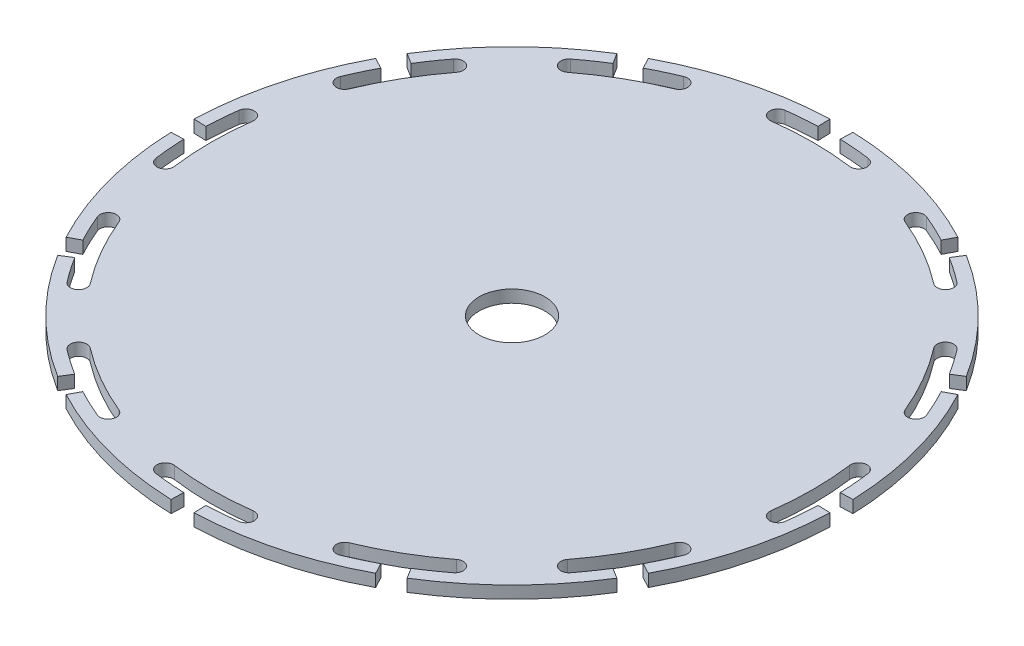
from build123d import *

# Parameters (mm, degrees)
SKETCH1_R         = 40
WHEEL_BLANK_DEPTH = 1.5
T_SLOT_DEPTH      = 2.5
CIRPATTERN_COUNT  = 12
SKETCH3_R         = 4
CENTER_HOLE_DEPTH = 6


with BuildPart() as part:
    # Sketch1 → Wheel Blank (new body)
    with BuildSketch(Plane(origin=(0, 0, 0), x_dir=(1, 0, 0), z_dir=(0, 1, 0))):
        Circle(SKETCH1_R)
    extrude(amount=WHEEL_BLANK_DEPTH)

    # Sketch2 → T-Slot (cut, through all)
    with BuildSketch(Plane(origin=(0, 0, 0), x_dir=(1, 0, 0), z_dir=(0, 1, 0))):
        with BuildLine():
            Line((-1.395979868, 39.975633081), (-1.343630623, 38.47654684))
            ThreePointArc((-1.343630623, 38.47654684), (-3.188115989, 38.367771846), (-5.0252584, 38.170627163))
            ThreePointArc((-5.0252584, 38.170627163), (-5.88617707, 37.048656109), (-4.764206016, 36.18773744))
            ThreePointArc((-4.764206016, 36.18773744), (0, 36.5), (4.764206016, 36.18773744))
            ThreePointArc((4.764206016, 36.18773744), (5.88617707, 37.048656109), (5.0252584, 38.170627163))
            ThreePointArc((5.0252584, 38.170627163), (3.188115989, 38.367771846), (1.343630623, 38.47654684))
            Line((1.343630623, 38.47654684), (1.395979868, 39.975633081))
            ThreePointArc((1.395979868, 39.975633081), (0, 40), (-1.395979868, 39.975633081))
        make_face()
    t_slot = extrude(amount=T_SLOT_DEPTH, mode=Mode.SUBTRACT)

    # CirPattern: T-Slot ×12 about axis
    cirpattern_axis = Axis((0, 0, 0), (0, 1, 0))
    for i in range(1, CIRPATTERN_COUNT):
        add(t_slot.rotate(cirpattern_axis, i * 360 / CIRPATTERN_COUNT), mode=Mode.SUBTRACT)

    # Sketch3 → Center Hole (cut)
    with BuildSketch(Plane(origin=(0, 0, 0), x_dir=(1, 0, 0), z_dir=(0, 1, 0))):
        Circle(SKETCH3_R)
    extrude(amount=CENTER_HOLE_DEPTH, mode=Mode.SUBTRACT)


solid = part.part
